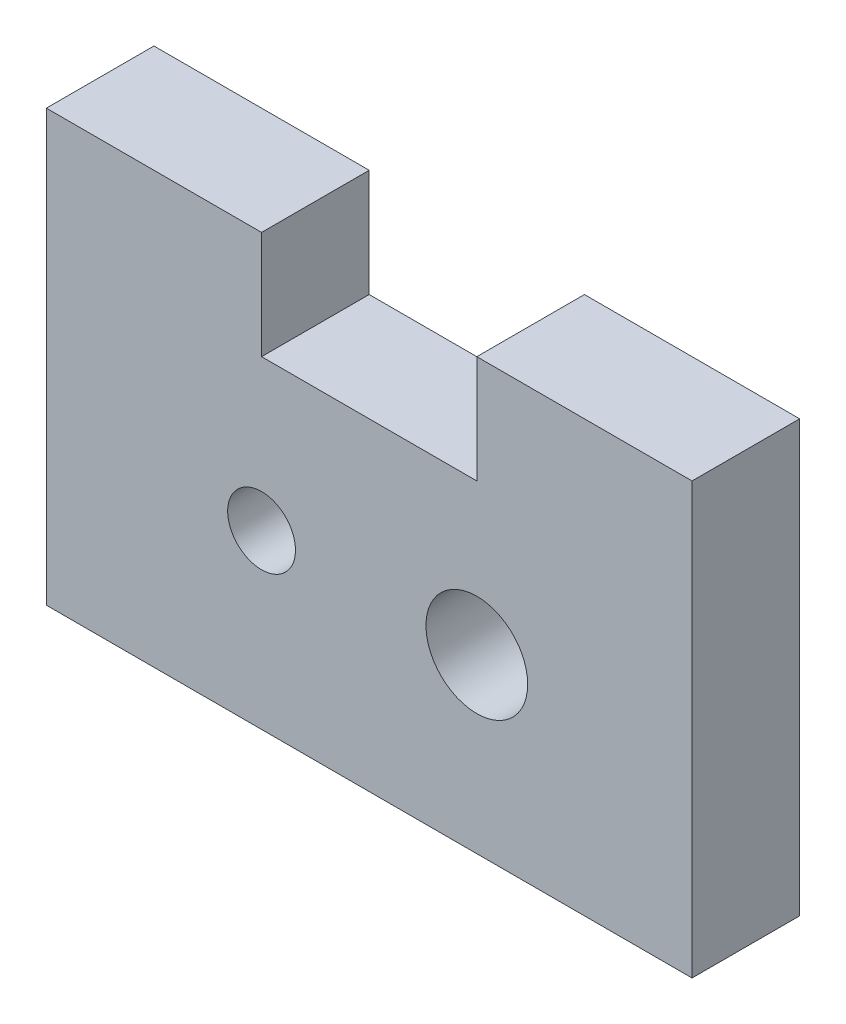
from build123d import *

# Parameters (mm, degrees)
SKETCH1_R           = 1.5
SKETCH1_R_2         = 1
BOSS_EXTRUDE1_DEPTH = 3.175


with BuildPart() as part:
    # Sketch1 → Boss-Extrude1 (new body)
    with BuildSketch(Plane.XY):
        Polygon((6.35, 12.7), (6.35, 9.525), (12.7, 9.525), (12.7, 12.7), (19.05, 12.7), (19.05, 0), (0, 0), (0, 12.7), align=None)
        with Locations((12.7, 5.08)):
            Circle(SKETCH1_R, mode=Mode.SUBTRACT)
        with Locations((6.35, 5.08)):
            Circle(SKETCH1_R_2, mode=Mode.SUBTRACT)
    extrude(amount=BOSS_EXTRUDE1_DEPTH)


solid = part.part
